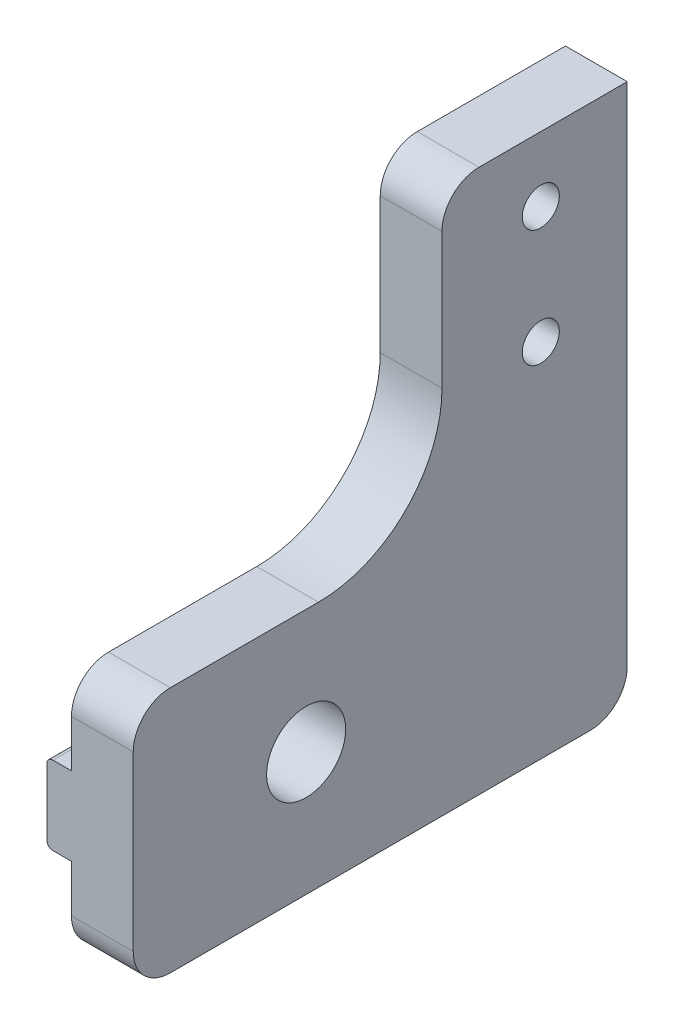
from build123d import *

# Parameters (mm, degrees)
SKETCH1_R           = 1.5
BOSS_EXTRUDE1_DEPTH = 5
SKETCH3_W           = 40
SKETCH3_H           = 6.35
BOSS_EXTRUDE2_DEPTH = 2
FILLET1_R           = 0.5
FILLET2_R           = 3
SKETCH4_R           = 3.2004
CUT_EXTRUDE1_DEPTH  = 8
FILLET3_R           = 10


with BuildPart() as part:
    # Sketch1 → Boss-Extrude1 (new body)
    with BuildSketch(Plane(origin=(0, 0, 0), x_dir=(0, 0, -1), z_dir=(1, 0, 0))):
        Polygon((0, 0), (0, 20), (25, 20), (25, 44), (40, 44), (40, 0), align=None)
        with Locations((33, 38.75)):
            Circle(SKETCH1_R, mode=Mode.SUBTRACT)
        with Locations((33, 29.25)):
            Circle(SKETCH1_R, mode=Mode.SUBTRACT)
    extrude(amount=BOSS_EXTRUDE1_DEPTH)

    # Sketch3 → Boss-Extrude2 (add)
    with BuildSketch(Plane.ZY):
        with Locations((-20, 10)):
            Rectangle(SKETCH3_W, SKETCH3_H)
    extrude(amount=BOSS_EXTRUDE2_DEPTH)

    # Fillet1
    fillet1_edges = [part.edges().sort_by_distance(p)[0] for p in [
        (-2, 6.825, -20),
        (-2, 13.175, -20),
    ]]
    fillet(fillet1_edges, radius=FILLET1_R)

    # Fillet2
    fillet2_edges = [part.edges().sort_by_distance(p)[0] for p in [
        (2.5, 0, 0),
        (2.5, 20, 0),
        (2.5, 44, -25),
        (2.5, 0, -40),
    ]]
    fillet(fillet2_edges, radius=FILLET2_R)

    # Sketch4 → Cut-Extrude1 (cut, through all)
    with BuildSketch(Plane(origin=(5, 0, 0), x_dir=(0, 0, -1), z_dir=(1, 0, 0))):
        with Locations((14, 10)):
            Circle(SKETCH4_R)
    extrude(amount=-CUT_EXTRUDE1_DEPTH, mode=Mode.SUBTRACT)

    # Fillet3
    fillet3_edges = [part.edges().sort_by_distance(p)[0] for p in [
        (2.5, 20, -25),
    ]]
    fillet(fillet3_edges, radius=FILLET3_R)


solid = part.part
